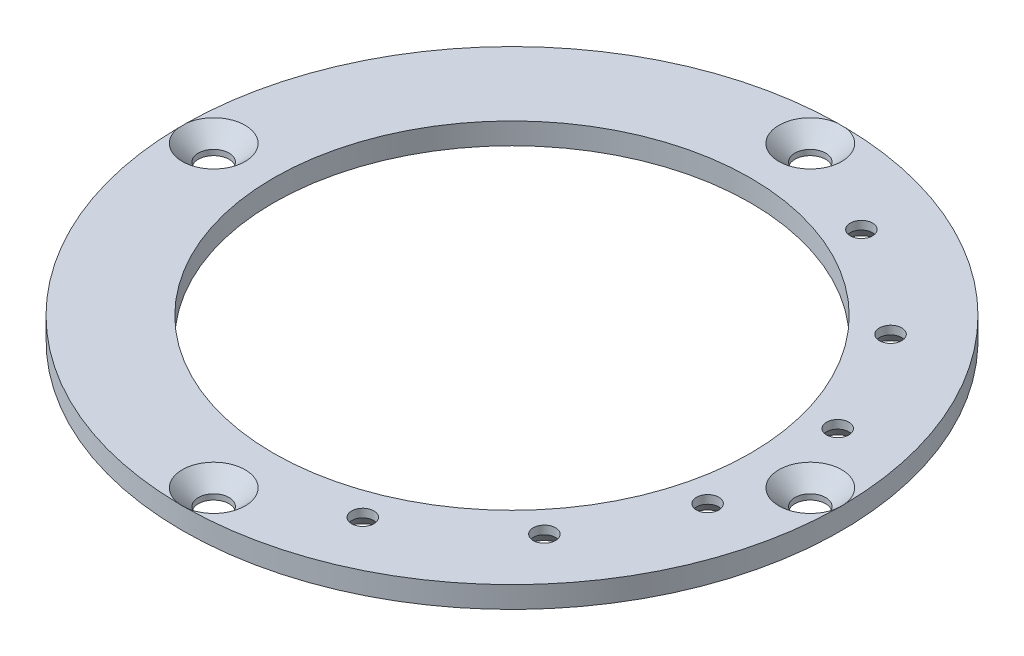
from build123d import *

# Parameters (mm, degrees)
SKETCH3_R                                      = 48.26
SKETCH3_R_2                                    = 34.925
BOSS_EXTRUDE1_DEPTH                            = 3.1496
CSK_FOR_M4_FLAT_HEAD_MACHINE_SCREW2_AT_2_COUNT = 2
CSK_FOR_M4_FLAT_HEAD_MACHINE_SCREW2_AT_2_PITCH = 61.784162113
CSK_FOR_M4_FLAT_HEAD_MACHINE_SCREW2_AT_3_COUNT = 2
CSK_FOR_M4_FLAT_HEAD_MACHINE_SCREW2_AT_3_PITCH = 87.376
CSK_FOR_M4_FLAT_HEAD_MACHINE_SCREW2_AT_4_COUNT = 2
CSK_FOR_M4_FLAT_HEAD_MACHINE_SCREW2_AT_4_PITCH = 61.784162113
CSK_FOR_4_FLAT_HEAD_MACHINE_SCREW1_AT_2_COUNT  = 2
CSK_FOR_4_FLAT_HEAD_MACHINE_SCREW1_AT_2_PITCH  = 19.05
CSK_FOR_4_FLAT_HEAD_MACHINE_SCREW1_AT_3_COUNT  = 2
CSK_FOR_4_FLAT_HEAD_MACHINE_SCREW1_AT_3_PITCH  = 35.79885845
CSK_FOR_4_FLAT_HEAD_MACHINE_SCREW1_AT_4_COUNT  = 2
CSK_FOR_4_FLAT_HEAD_MACHINE_SCREW1_AT_4_PITCH  = 51.698767879
CSK_FOR_4_FLAT_HEAD_MACHINE_SCREW1_AT_5_COUNT  = 2
CSK_FOR_4_FLAT_HEAD_MACHINE_SCREW1_AT_5_PITCH  = 63.760255082
CSK_FOR_4_FLAT_HEAD_MACHINE_SCREW1_AT_6_COUNT  = 2
CSK_FOR_4_FLAT_HEAD_MACHINE_SCREW1_AT_6_PITCH  = 73.02909889


with BuildPart() as part:
    # Sketch3 → Boss-Extrude1 (new body)
    with BuildSketch(Plane(origin=(0, -40.33266, 0), x_dir=(1, 0, 0), z_dir=(0, 1, 0))):
        Circle(SKETCH3_R)
        Circle(SKETCH3_R_2, mode=Mode.SUBTRACT)
    extrude(amount=-BOSS_EXTRUDE1_DEPTH)

    # Sketch18 → CSK for M4 Flat Head Machine Screw2 (revolve, cut)
    with BuildSketch(Plane(origin=(0, -40.33266, 43.688), x_dir=(0, 0, 1), z_dir=(1, 0, 0))):
        Polygon((0, 0), (0, 3.1496), (2.25, 3.1496), (2.25, 2.35), (4.6, 0), align=None)
    csk_for_m4_flat_head_machine_screw2 = revolve(axis=Axis((0, -33.98266, 43.688), (0, -1, 0)), mode=Mode.SUBTRACT)

    # CSK for M4 Flat Head Machine Screw2 at 2: CSK for M4 Flat Head Machine Screw2 ×2
    with Locations(*[Vector(0.707106781, 0, -0.707106781) * (i * CSK_FOR_M4_FLAT_HEAD_MACHINE_SCREW2_AT_2_PITCH) for i in range(1, CSK_FOR_M4_FLAT_HEAD_MACHINE_SCREW2_AT_2_COUNT)]):
        add(csk_for_m4_flat_head_machine_screw2, mode=Mode.SUBTRACT)

    # CSK for M4 Flat Head Machine Screw2 at 3: CSK for M4 Flat Head Machine Screw2 ×2
    with Locations(*[(0, 0, -i * CSK_FOR_M4_FLAT_HEAD_MACHINE_SCREW2_AT_3_PITCH) for i in range(1, CSK_FOR_M4_FLAT_HEAD_MACHINE_SCREW2_AT_3_COUNT)]):
        add(csk_for_m4_flat_head_machine_screw2, mode=Mode.SUBTRACT)

    # CSK for M4 Flat Head Machine Screw2 at 4: CSK for M4 Flat Head Machine Screw2 ×2
    with Locations(*[Vector(-0.707106781, 0, -0.707106781) * (i * CSK_FOR_M4_FLAT_HEAD_MACHINE_SCREW2_AT_4_PITCH) for i in range(1, CSK_FOR_M4_FLAT_HEAD_MACHINE_SCREW2_AT_4_COUNT)]):
        add(csk_for_m4_flat_head_machine_screw2, mode=Mode.SUBTRACT)

    # Sketch9 → CSK for #4 Flat Head Machine Screw1 (revolve, cut)
    with BuildSketch(Plane(origin=(14.657877005, -43.48226, 36.514549445), x_dir=(0, 0, -1), z_dir=(1, 0, 0))):
        Polygon((0, 0), (0, 3.1496), (1.63195, 3.1496), (1.63195, 1.921172758), (3.302, 0), align=None)
    csk_for_4_flat_head_machine_screw1 = revolve(axis=Axis((14.657877005, -49.83226, 36.514549445), (0, 1, 0)), mode=Mode.SUBTRACT)

    # CSK for #4 Flat Head Machine Screw1 at 2: CSK for #4 Flat Head Machine Screw1 ×2
    with Locations(*[Vector(0.810235621, 0, -0.58610429) * (i * CSK_FOR_4_FLAT_HEAD_MACHINE_SCREW1_AT_2_PITCH) for i in range(1, CSK_FOR_4_FLAT_HEAD_MACHINE_SCREW1_AT_2_COUNT)]):
        add(csk_for_4_flat_head_machine_screw1, mode=Mode.SUBTRACT)

    # CSK for #4 Flat Head Machine Screw1 at 3: CSK for #4 Flat Head Machine Screw1 ×2
    with Locations(*[Vector(0.65696386, 0, -0.753922069) * (i * CSK_FOR_4_FLAT_HEAD_MACHINE_SCREW1_AT_3_PITCH) for i in range(1, CSK_FOR_4_FLAT_HEAD_MACHINE_SCREW1_AT_3_COUNT)]):
        add(csk_for_4_flat_head_machine_screw1, mode=Mode.SUBTRACT)

    # CSK for #4 Flat Head Machine Screw1 at 4: CSK for #4 Flat Head Machine Screw1 ×2
    with Locations(*[Vector(0.454915217, 0, -0.890534752) * (i * CSK_FOR_4_FLAT_HEAD_MACHINE_SCREW1_AT_4_PITCH) for i in range(1, CSK_FOR_4_FLAT_HEAD_MACHINE_SCREW1_AT_4_COUNT)]):
        add(csk_for_4_flat_head_machine_screw1, mode=Mode.SUBTRACT)

    # CSK for #4 Flat Head Machine Screw1 at 5: CSK for #4 Flat Head Machine Screw1 ×2
    with Locations(*[Vector(0.242078526, 0, -0.97025666) * (i * CSK_FOR_4_FLAT_HEAD_MACHINE_SCREW1_AT_5_PITCH) for i in range(1, CSK_FOR_4_FLAT_HEAD_MACHINE_SCREW1_AT_5_COUNT)]):
        add(csk_for_4_flat_head_machine_screw1, mode=Mode.SUBTRACT)

    # CSK for #4 Flat Head Machine Screw1 at 6: CSK for #4 Flat Head Machine Screw1 ×2
    with Locations(*[(0, 0, -i * CSK_FOR_4_FLAT_HEAD_MACHINE_SCREW1_AT_6_PITCH) for i in range(1, CSK_FOR_4_FLAT_HEAD_MACHINE_SCREW1_AT_6_COUNT)]):
        add(csk_for_4_flat_head_machine_screw1, mode=Mode.SUBTRACT)


solid = part.part
